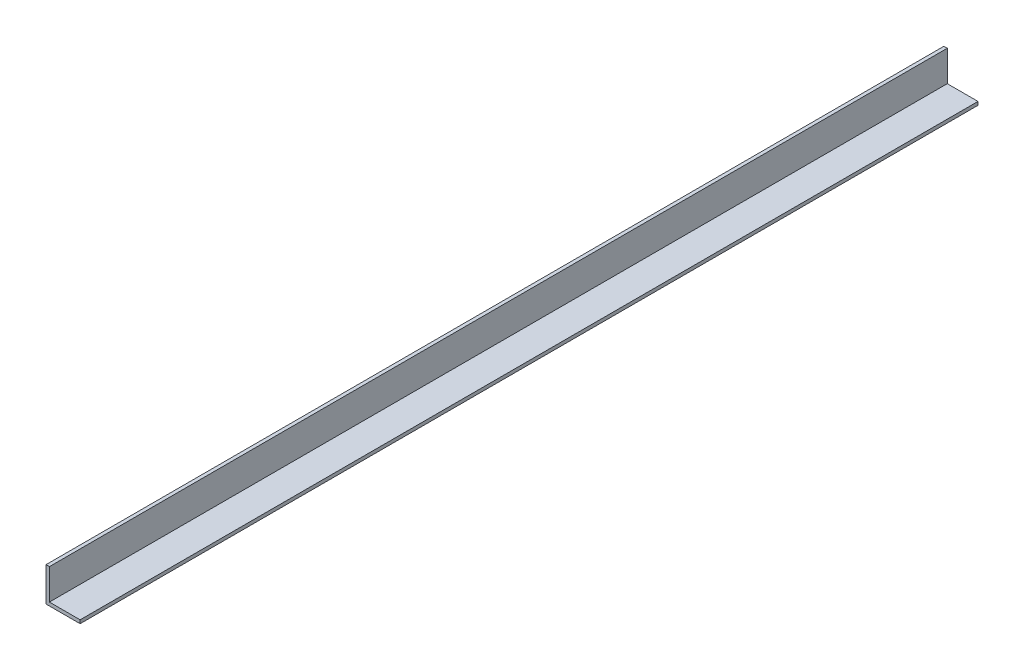
from build123d import *

# Parameters (mm, degrees)
EXTRUDE_1_DEPTH = 1000


with BuildPart() as part:
    # Эскиз1 → Бобышка-Вытянуть1 (new body)
    with BuildSketch(Plane.XY):
        Polygon((0, 38), (0, 0), (38, 0), (38, 3.8), (3.8, 3.8), (3.8, 38), align=None)
    extrude(amount=EXTRUDE_1_DEPTH)


solid = part.part
